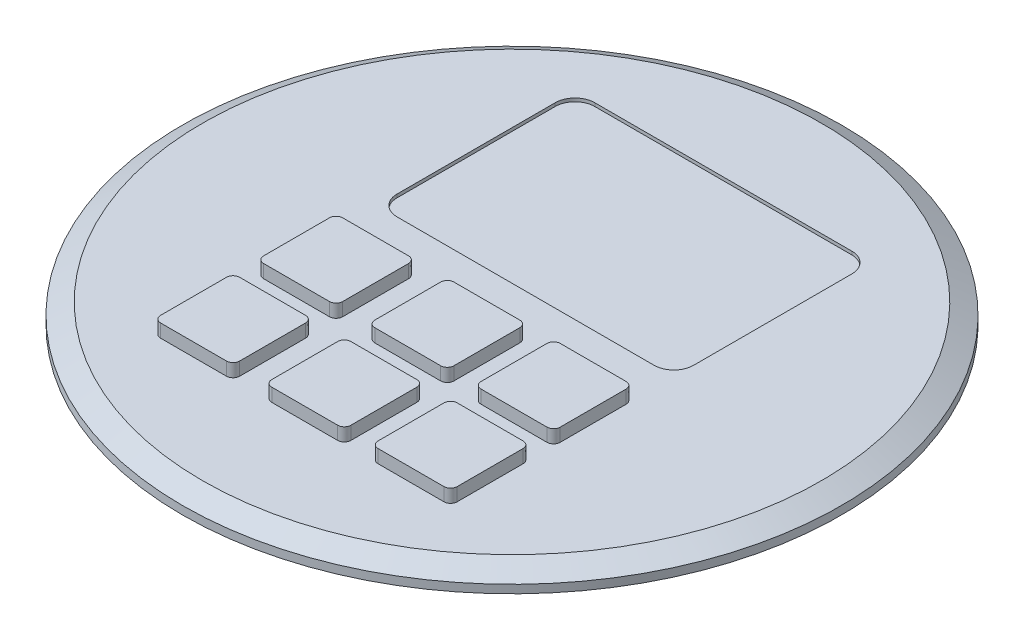
from build123d import *

# Parameters (mm, degrees)
SKETCH1_R           = 50
BOSS_EXTRUDE1_DEPTH = 3
CHAMFER1_SIZE       = 1.75
CHAMFER1_SIZE2      = 3.031088913
BOSS_EXTRUDE2_DEPTH = 2
CUT_EXTRUDE1_DEPTH  = 0.5


with BuildPart() as part:
    # Sketch1 → Boss-Extrude1 (new body)
    with BuildSketch(Plane(origin=(0, 0, 0), x_dir=(1, 0, 0), z_dir=(0, 1, 0))):
        Circle(SKETCH1_R)
    extrude(amount=BOSS_EXTRUDE1_DEPTH)

    # Chamfer1
    chamfer1_edges = [part.edges().sort_by_distance(p)[0] for p in [
        (-50, 3, 0),
    ]]
    chamfer1_side = [part.faces().sort_by_distance(p)[0] for p in [
        (-50, 1.5, 0),
    ]]
    chamfer(chamfer1_edges, length=CHAMFER1_SIZE, length2=CHAMFER1_SIZE2, reference=chamfer1_side[0])

    # Sketch2 → Boss-Extrude2 (add)
    with BuildSketch(Plane(origin=(0, 3, 0), x_dir=(1, 0, 0), z_dir=(0, 1, 0))):
        with BuildLine():
            Line((11.103734019, -15.794469399), (21.103734019, -15.794469399))
            ThreePointArc((21.103734019, -15.794469399), (21.8108408, -15.50157618), (22.103734019, -14.794469399))
            Line((22.103734019, -14.794469399), (22.103734019, -4.794469399))
            ThreePointArc((22.103734019, -4.794469399), (21.8108408, -4.087362618), (21.103734019, -3.794469399))
            Line((21.103734019, -3.794469399), (11.103734019, -3.794469399))
            ThreePointArc((11.103734019, -3.794469399), (10.396627238, -4.087362618), (10.103734019, -4.794469399))
            Line((10.103734019, -4.794469399), (10.103734019, -14.794469399))
            ThreePointArc((10.103734019, -14.794469399), (10.396627238, -15.50157618), (11.103734019, -15.794469399))
        make_face()
        with BuildLine():
            Line((-21.896265981, -3.794469399), (-11.896265981, -3.794469399))
            ThreePointArc((-11.896265981, -3.794469399), (-11.1891592, -4.087362618), (-10.896265981, -4.794469399))
            Line((-10.896265981, -4.794469399), (-10.896265981, -14.794469399))
            ThreePointArc((-10.896265981, -14.794469399), (-11.1891592, -15.50157618), (-11.896265981, -15.794469399))
            Line((-11.896265981, -15.794469399), (-21.896265981, -15.794469399))
            ThreePointArc((-21.896265981, -15.794469399), (-22.603372762, -15.50157618), (-22.896265981, -14.794469399))
            Line((-22.896265981, -14.794469399), (-22.896265981, -4.794469399))
            ThreePointArc((-22.896265981, -4.794469399), (-22.603372762, -4.087362618), (-21.896265981, -3.794469399))
        make_face()
        with BuildLine():
            Line((-6.023330141, -4.794469399), (-6.023330141, -14.794469399))
            ThreePointArc((-6.023330141, -14.794469399), (-5.730436923, -15.50157618), (-5.023330141, -15.794469399))
            Line((-5.023330141, -15.794469399), (4.976669859, -15.794469399))
            ThreePointArc((4.976669859, -15.794469399), (5.68377664, -15.50157618), (5.976669859, -14.794469399))
            Line((5.976669859, -14.794469399), (5.976669859, -4.794469399))
            ThreePointArc((5.976669859, -4.794469399), (5.68377664, -4.087362618), (4.976669859, -3.794469399))
            Line((4.976669859, -3.794469399), (-5.023330141, -3.794469399))
            ThreePointArc((-5.023330141, -3.794469399), (-5.730436923, -4.087362618), (-6.023330141, -4.794469399))
        make_face()
        with BuildLine():
            Line((22.103734019, -30.422865031), (22.103734019, -20.422865031))
            ThreePointArc((22.103734019, -20.422865031), (21.8108408, -19.715758249), (21.103734019, -19.422865031))
            Line((21.103734019, -19.422865031), (11.103734019, -19.422865031))
            ThreePointArc((11.103734019, -19.422865031), (10.396627238, -19.715758249), (10.103734019, -20.422865031))
            Line((10.103734019, -20.422865031), (10.103734019, -30.422865031))
            ThreePointArc((10.103734019, -30.422865031), (10.396627238, -31.129971812), (11.103734019, -31.422865031))
            Line((11.103734019, -31.422865031), (21.103734019, -31.422865031))
            ThreePointArc((21.103734019, -31.422865031), (21.8108408, -31.129971812), (22.103734019, -30.422865031))
        make_face()
        with BuildLine():
            Line((-5.023330141, -31.422865031), (4.976669859, -31.422865031))
            ThreePointArc((4.976669859, -31.422865031), (5.68377664, -31.129971812), (5.976669859, -30.422865031))
            Line((5.976669859, -30.422865031), (5.976669859, -20.422865031))
            ThreePointArc((5.976669859, -20.422865031), (5.68377664, -19.715758249), (4.976669859, -19.422865031))
            Line((4.976669859, -19.422865031), (-5.023330141, -19.422865031))
            ThreePointArc((-5.023330141, -19.422865031), (-5.730436923, -19.715758249), (-6.023330141, -20.422865031))
            Line((-6.023330141, -20.422865031), (-6.023330141, -30.422865031))
            ThreePointArc((-6.023330141, -30.422865031), (-5.730436923, -31.129971812), (-5.023330141, -31.422865031))
        make_face()
        with BuildLine():
            Line((-21.896265981, -19.422865031), (-11.896265981, -19.422865031))
            ThreePointArc((-11.896265981, -19.422865031), (-11.1891592, -19.715758249), (-10.896265981, -20.422865031))
            Line((-10.896265981, -20.422865031), (-10.896265981, -30.422865031))
            ThreePointArc((-10.896265981, -30.422865031), (-11.1891592, -31.129971812), (-11.896265981, -31.422865031))
            Line((-11.896265981, -31.422865031), (-21.896265981, -31.422865031))
            ThreePointArc((-21.896265981, -31.422865031), (-22.603372762, -31.129971812), (-22.896265981, -30.422865031))
            Line((-22.896265981, -30.422865031), (-22.896265981, -20.422865031))
            ThreePointArc((-22.896265981, -20.422865031), (-22.603372762, -19.715758249), (-21.896265981, -19.422865031))
        make_face()
    extrude(amount=BOSS_EXTRUDE2_DEPTH)

    # Sketch3 → Cut-Extrude1 (cut)
    with BuildSketch(Plane(origin=(0, 3, 0), x_dir=(1, 0, 0), z_dir=(0, 1, 0))):
        with BuildLine():
            Line((-19.896265981, 32.453863143), (19.103734019, 32.453863143))
            ThreePointArc((19.103734019, 32.453863143), (21.225054363, 31.575183487), (22.103734019, 29.453863143))
            Line((22.103734019, 29.453863143), (22.103734019, 5.453863143))
            ThreePointArc((22.103734019, 5.453863143), (21.225054363, 3.3325428), (19.103734019, 2.453863143))
            Line((19.103734019, 2.453863143), (-19.896265981, 2.453863143))
            ThreePointArc((-19.896265981, 2.453863143), (-22.017586324, 3.3325428), (-22.896265981, 5.453863143))
            Line((-22.896265981, 5.453863143), (-22.896265981, 29.453863143))
            ThreePointArc((-22.896265981, 29.453863143), (-22.017586324, 31.575183487), (-19.896265981, 32.453863143))
        make_face()
    extrude(amount=-CUT_EXTRUDE1_DEPTH, mode=Mode.SUBTRACT)


solid = part.part
